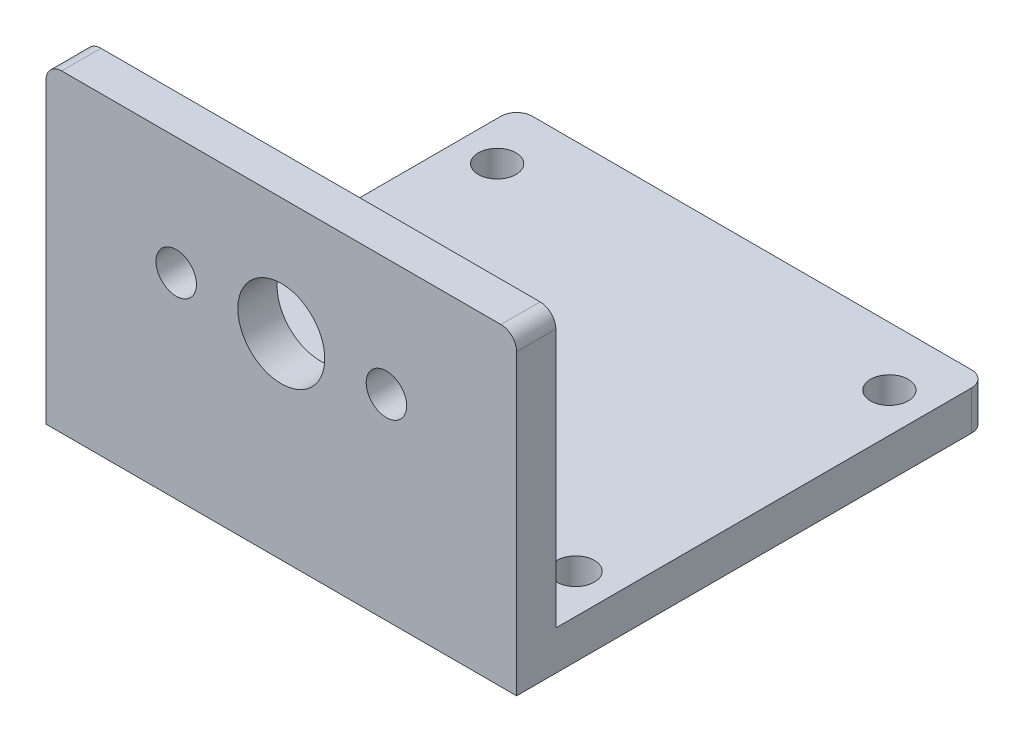
from build123d import *

# Parameters (mm, degrees)
BOSS_EXTRUDE1_DEPTH = 38.1
SKETCH3_R           = 3.5179
SKETCH3_R_2         = 1.6383
CUT_EXTRUDE1_DEPTH  = 4.175
FILLET1_R           = 1.27
SKETCH4_R           = 1.524
CUT_EXTRUDE2_DEPTH  = 4.175


with BuildPart() as part:
    # Sketch2 → Boss-Extrude1 (new body)
    with BuildSketch(Plane(origin=(0, 0, 0), x_dir=(0, 0, -1), z_dir=(1, 0, 0))):
        Polygon((0, 0), (38.1, 0), (38.1, 3.175), (3.175, 3.175), (3.175, 25.4), (0, 25.4), align=None)
    extrude(amount=BOSS_EXTRUDE1_DEPTH)

    # Sketch3 → Cut-Extrude1 (cut, through all)
    with BuildSketch(Plane(origin=(0, 0, -3.175), x_dir=(-1, 0, 0), z_dir=(0, 0, -1))):
        with Locations((-19.05, 15.875)):
            Circle(SKETCH3_R)
        with Locations((-10.541, 15.875)):
            Circle(SKETCH3_R_2)
        with Locations((-27.559, 15.875)):
            Circle(SKETCH3_R_2)
    extrude(amount=-CUT_EXTRUDE1_DEPTH, mode=Mode.SUBTRACT)

    # Fillet1
    fillet1_edges = [part.edges().sort_by_distance(p)[0] for p in [
        (38.1, 1.5875, -38.1),
        (38.1, 25.4, -1.5875),
        (0, 25.4, -1.5875),
        (0, 1.5875, -38.1),
    ]]
    fillet(fillet1_edges, radius=FILLET1_R)

    # Sketch4 → Cut-Extrude2 (cut, through all)
    with BuildSketch(Plane(origin=(0, 3.175, 0), x_dir=(1, 0, 0), z_dir=(0, 1, 0))):
        with Locations((3.175, 7.9502)):
            Circle(SKETCH4_R)
        with Locations((3.175, 33.3502)):
            Circle(SKETCH4_R)
        with Locations((34.925, 33.3502)):
            Circle(SKETCH4_R)
        with Locations((34.925, 7.9502)):
            Circle(SKETCH4_R)
    extrude(amount=-CUT_EXTRUDE2_DEPTH, mode=Mode.SUBTRACT)


solid = part.part
